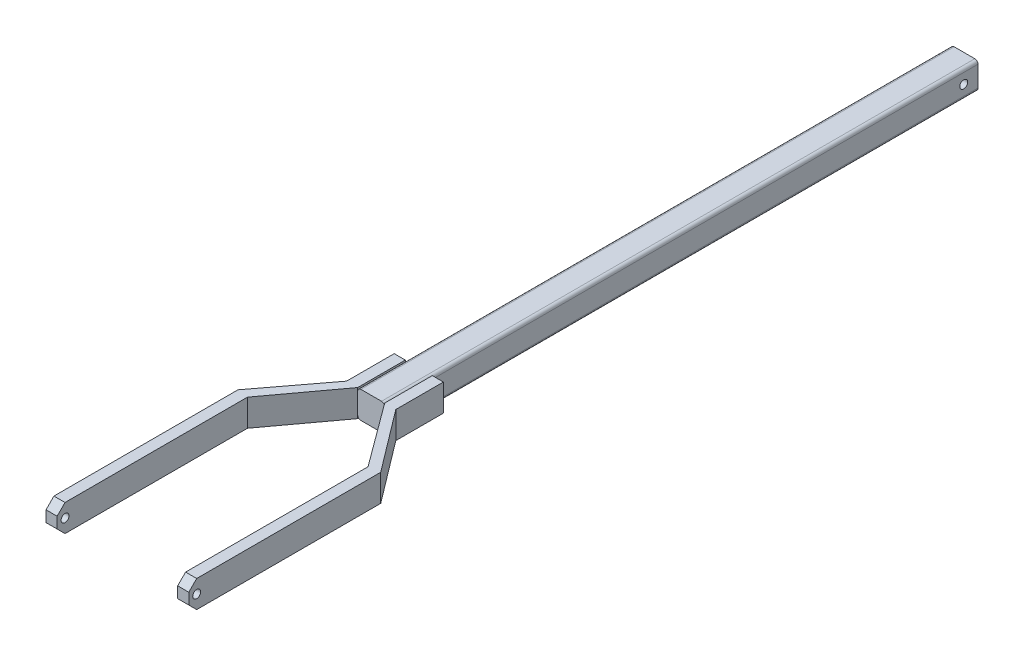
from build123d import *

# Parameters (mm, degrees)
EXTRUDE1_DEPTH = 374
EXTRUDE2_DEPTH = 17
SKETCH4_R      = 2.5
EXTRUDE3_DEPTH = 91


with BuildPart() as part:
    # Sketch1 → Extrude1 (new body)
    with BuildSketch(Plane.XY):
        with BuildLine():
            Line((-38.142101627, 26.909417684), (-25.142101627, 26.909417684))
            ThreePointArc((-25.142101627, 26.909417684), (-23.727888065, 26.323631246), (-23.142101627, 24.909417684))
            Line((-23.142101627, 24.909417684), (-23.142101627, 11.909417684))
            ThreePointArc((-23.142101627, 11.909417684), (-23.727888065, 10.495204122), (-25.142101627, 9.909417684))
            Line((-25.142101627, 9.909417684), (-38.142101627, 9.909417684))
            ThreePointArc((-38.142101627, 9.909417684), (-39.55631519, 10.495204122), (-40.142101627, 11.909417684))
            Line((-40.142101627, 11.909417684), (-40.142101627, 24.909417684))
            ThreePointArc((-40.142101627, 24.909417684), (-39.55631519, 26.323631246), (-38.142101627, 26.909417684))
        make_face()
    extrude(amount=EXTRUDE1_DEPTH)

    # Sketch2 → Extrude2 (add)
    with BuildSketch(Plane(origin=(0, 26.909417684, 0), x_dir=(1, 0, 0), z_dir=(0, 1, 0))):
        Polygon((-23.142101627, -374), (-23.142101627, -344), (-16.142101627, -344), (-16.142101627, -374), (13.357898373, -413), (13.357898373, -534), (6.357898373, -534), (6.357898373, -414), align=None)
        Polygon((-40.142101627, -374), (-40.142101627, -344), (-47.142101627, -344), (-47.142101627, -374), (-76.642101627, -413), (-76.642101627, -534), (-69.642101627, -534), (-69.642101627, -414), align=None)
    extrude(amount=-EXTRUDE2_DEPTH)

    # Sketch4 → Extrude3 (cut, through all)
    with BuildSketch(Plane(origin=(13.357898373, 0, 0), x_dir=(0, 0, -1), z_dir=(1, 0, 0))):
        with Locations((-529, 18.409417684)):
            Circle(SKETCH4_R)
        with Locations((-9, 18.409417684)):
            Circle(SKETCH4_R)
        Polygon((-529, 26.909417684), (-534, 21.909417684), (-534, 14.909417684), (-529, 9.909417684), (-529, 0), (-556.33894416, 6.720406123), (-552.141138814, 40.050556498), (-531.5, 37.450883772), align=None)
    extrude(amount=-EXTRUDE3_DEPTH, mode=Mode.SUBTRACT)


solid = part.part
